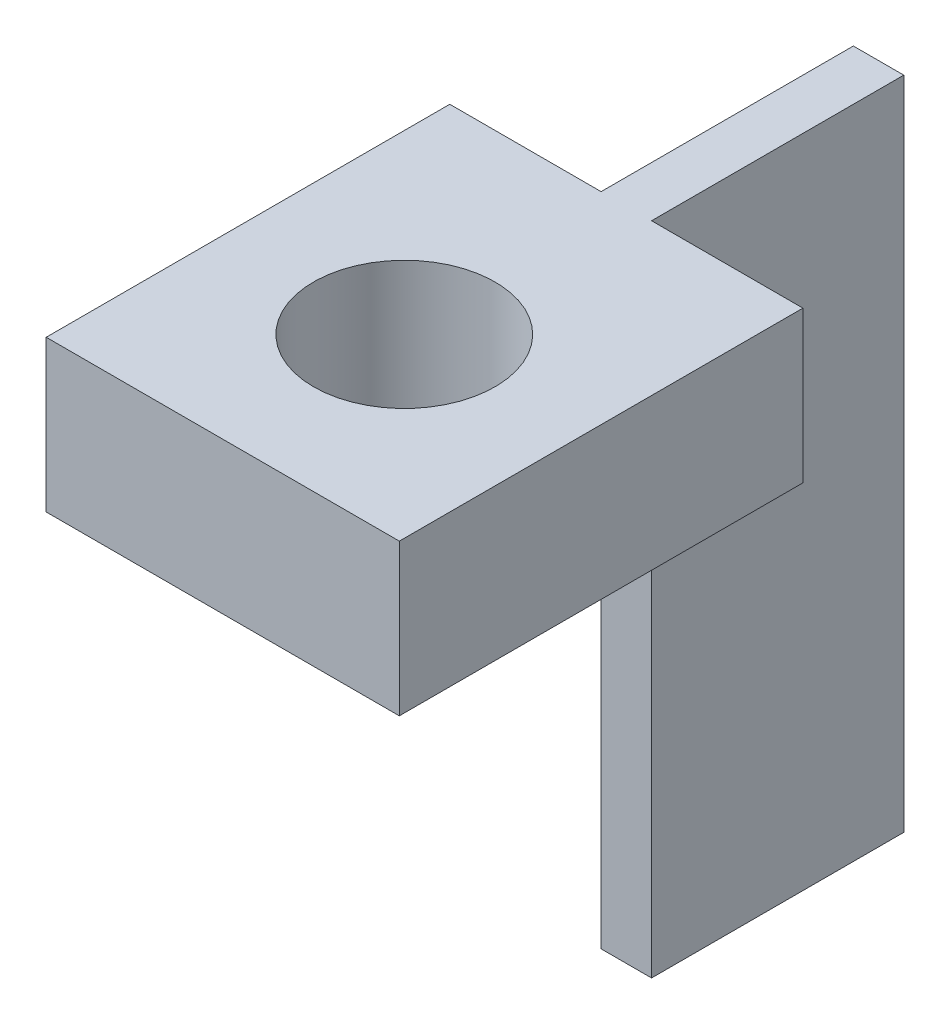
from build123d import *

# Parameters (mm, degrees)
BOSS_EXTRUDE1_DEPTH  = 0.5
SKETCH2_W            = 7
SKETCH2_H            = 8
BOSS_EXTRUDE2_DEPTH  = 3
M3_CLEARANCE_HOLE1_D = 3.6


with BuildPart() as part:
    # Sketch1 → Boss-Extrude1 (new body, symmetric)
    with BuildSketch(Plane(origin=(0, 0, 0), x_dir=(0, 0, -1), z_dir=(1, 0, 0))):
        Polygon((0, 0), (0, 10), (-8, 10), (-8, 13), (5, 13), (5, 0), align=None)
    extrude(amount=BOSS_EXTRUDE1_DEPTH, both=True)

    # Sketch2 → Boss-Extrude2 (add, through all)
    with BuildSketch(Plane.XZ.offset(-10)):
        with Locations((0, 4)):
            Rectangle(SKETCH2_W, SKETCH2_H)
    extrude(amount=-BOSS_EXTRUDE2_DEPTH)

    # M3 Clearance Hole1 (through all)
    with Locations(Plane(origin=(0, 13, 0), x_dir=(1, 0, 0), z_dir=(0, 1, 0))):
        with Locations((0, -4.401597527)):
            Hole(M3_CLEARANCE_HOLE1_D / 2)


solid = part.part
